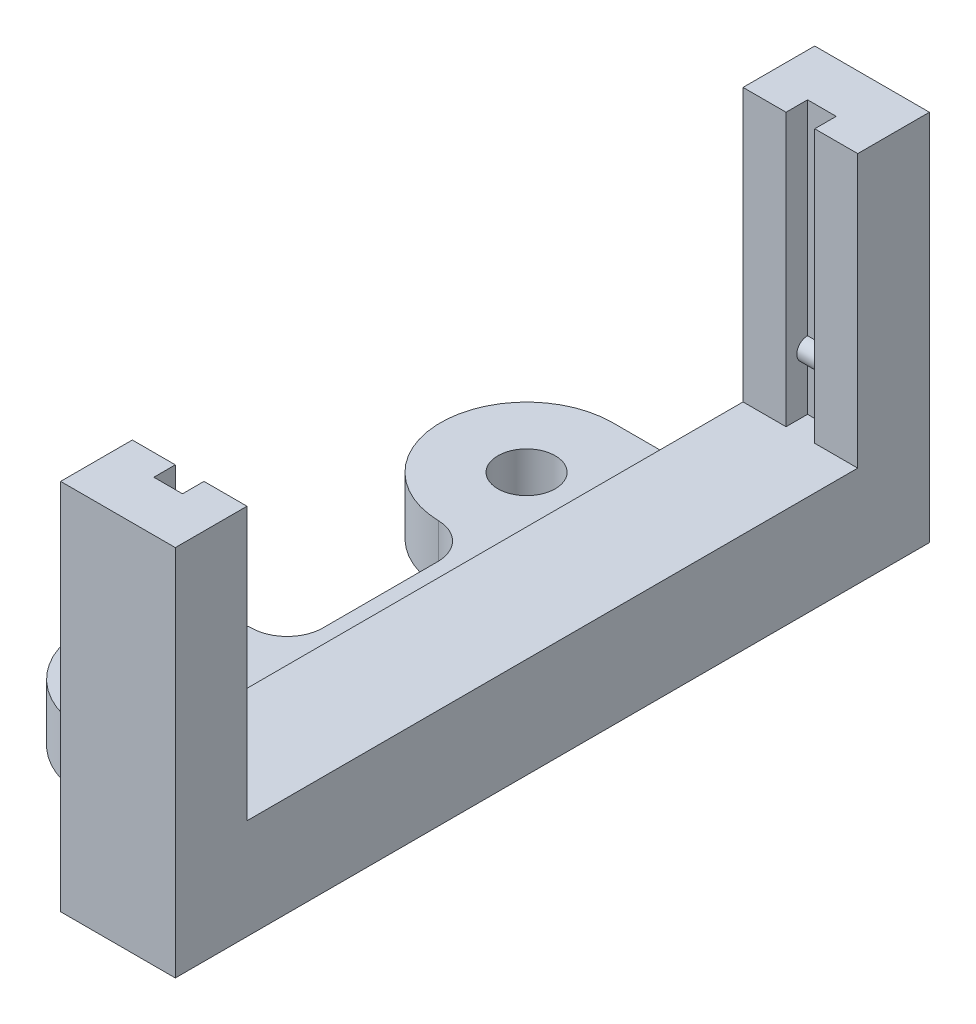
from build123d import *

# Parameters (mm, degrees)
SKETCH1_R           = 2
BOSS_EXTRUDE1_DEPTH = 4
SKETCH1_3_W         = 8
SKETCH1_3_H         = 18.5
SKETCH1_3_H_2       = 7.8
BOSS_EXTRUDE2_DEPTH = 7
BOSS_EXTRUDE3_DEPTH = 22
BOSS_EXTRUDE4_DEPTH = 2
FILLET1_R           = 2.5


with BuildPart() as part:
    # Sketch1 → Boss-Extrude1 (new body)
    with BuildSketch(Plane(origin=(0, 0, 0), x_dir=(1, 0, 0), z_dir=(0, 1, 0))):
        with BuildLine():
            Line((28.947984737, 18.5), (22.647984737, 18.5))
            ThreePointArc((22.647984737, 18.5), (16.647984737, 12.5), (22.647984737, 6.5))
            Line((22.647984737, 6.5), (24.947984737, 6.5))
            Line((24.947984737, 6.5), (24.947984737, -6.5))
            Line((24.947984737, -6.5), (22.647984737, -6.5))
            ThreePointArc((22.647984737, -6.5), (16.647984737, -12.5), (22.647984737, -18.5))
            Line((22.647984737, -18.5), (28.947984737, -18.5))
            Line((28.947984737, -18.5), (28.947984737, 18.5))
        make_face()
        with Locations((22.647984737, 12.5)):
            Circle(SKETCH1_R, mode=Mode.SUBTRACT)
        with Locations((22.647984737, -12.5)):
            Circle(SKETCH1_R, mode=Mode.SUBTRACT)
    extrude(amount=BOSS_EXTRUDE1_DEPTH)

    # Sketch1_3 → Boss-Extrude2 (add)
    with BuildSketch(Plane(origin=(0, 0, 0), x_dir=(1, 0, 0), z_dir=(0, 1, 0))):
        with Locations((32.947984737, 9.25)):
            Rectangle(SKETCH1_3_W, SKETCH1_3_H)
        with Locations((32.947984737, -9.25)):
            Rectangle(SKETCH1_3_W, SKETCH1_3_H)
        with Locations((32.947984737, 22.4)):
            Rectangle(SKETCH1_3_W, SKETCH1_3_H_2)
        with Locations((32.947984737, -22.4)):
            Rectangle(SKETCH1_3_W, SKETCH1_3_H_2)
    extrude(amount=BOSS_EXTRUDE2_DEPTH)

    # Sketch5 → Boss-Extrude3 (add)
    with BuildSketch(Plane(origin=(0, 4, 0), x_dir=(1, 0, 0), z_dir=(0, 1, 0))):
        Polygon((31.947984737, 21.3), (31.947984737, 22.8), (32.947984737, 22.8), (32.947984737, 26.3), (28.947984737, 26.3), (28.947984737, 21.3), align=None)
        Polygon((32.947984737, 26.3), (32.947984737, 22.8), (33.947984737, 22.8), (33.947984737, 21.3), (36.947984737, 21.3), (36.947984737, 26.3), align=None)
        Polygon((36.947984737, -26.3), (36.947984737, -21.3), (33.947984737, -21.3), (33.947984737, -22.8), (32.947984737, -22.8), (32.947984737, -26.3), align=None)
        Polygon((28.947984737, -26.3), (32.947984737, -26.3), (32.947984737, -22.8), (31.947984737, -22.8), (31.947984737, -21.3), (28.947984737, -21.3), align=None)
    extrude(amount=BOSS_EXTRUDE3_DEPTH)

    # Sketch6 → Boss-Extrude4 (add)
    with BuildSketch(Plane(origin=(31.947984737, 0, 0), x_dir=(0, 0, -1), z_dir=(1, 0, 0))):
        with BuildLine():
            Line((22.8, 10.25), (22.8, 11.75))
            ThreePointArc((22.8, 11.75), (22.05, 11), (22.8, 10.25))
        make_face()
        with BuildLine():
            ThreePointArc((-22.8, 11.75), (-22.05, 11), (-22.8, 10.25))
            Line((-22.8, 10.25), (-22.8, 11.75))
        make_face()
    extrude(amount=BOSS_EXTRUDE4_DEPTH)

    # Fillet1
    fillet1_edges = [part.edges().sort_by_distance(p)[0] for p in [
        (28.947984737, 2, 18.5),
        (24.947984737, 2, 6.5),
        (24.947984737, 2, -6.5),
        (28.947984737, 2, -18.5),
    ]]
    fillet(fillet1_edges, radius=FILLET1_R)


solid = part.part
